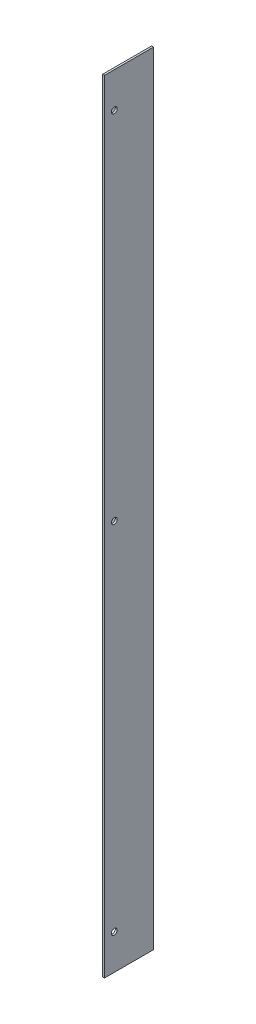
from build123d import *

# Parameters (mm, degrees)
CROQUIS2_W              = 1
CROQUIS2_H              = 400
SALIENTE_EXTRUIR2_DEPTH = 25
CROQUIS5_R              = 1.5
CORTAR_EXTRUIR2_DEPTH   = 1
CROQUIS1_R              = 1.5
SALIENTE_EXTRUIR3_DEPTH = 1


with BuildPart() as part:
    # Croquis2 → Saliente-Extruir2 (new body)
    with BuildSketch(Plane.XY):
        with Locations((-54.941785307, -92.819624774)):
            Rectangle(CROQUIS2_W, CROQUIS2_H)
    extrude(amount=SALIENTE_EXTRUIR2_DEPTH)

    # Croquis5 → Cortar-Extruir2 (cut)
    with BuildSketch(Plane(origin=(-54.441785307, 0, 0), x_dir=(0, 0, -1), z_dir=(1, 0, 0))):
        with Locations((-20, 89.180375226)):
            Circle(CROQUIS5_R)
        with Locations((-20, -274.819624774)):
            Circle(CROQUIS5_R)
        with Locations((-20, -92.819624774)):
            Circle(CROQUIS5_R)
    extrude(amount=-CORTAR_EXTRUIR2_DEPTH, mode=Mode.SUBTRACT)

    # Croquis1 → Saliente-Extruir3 (add)
    with BuildSketch(Plane.XY):
        Polygon((-79.441785307, 83.180375226), (-79.441785307, -268.819624774), (-55.441785307, -292.819624774), (-55.441785307, 107.180375226), align=None)
        with Locations((-74.441785307, 47.180375226)):
            Circle(CROQUIS1_R, mode=Mode.SUBTRACT)
        with Locations((-74.441785307, -232.819624774)):
            Circle(CROQUIS1_R, mode=Mode.SUBTRACT)
    extrude(amount=SALIENTE_EXTRUIR3_DEPTH)


solid = part.part
